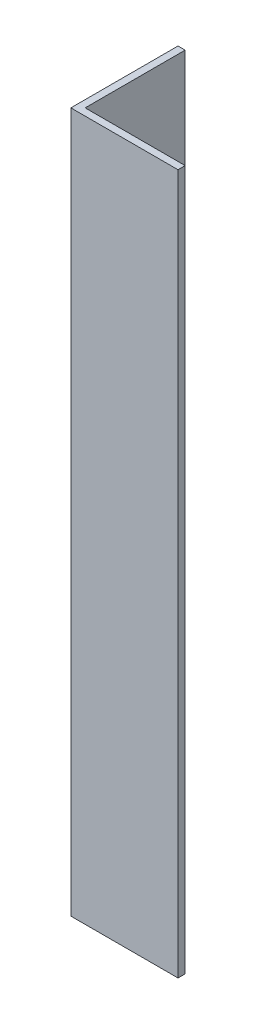
from build123d import *

# Parameters (mm, degrees)
EXTRUDE_1_DEPTH = 98


with BuildPart() as part:
    # Эскиз1 → Бобышка-Вытянуть1 (new body)
    with BuildSketch(Plane(origin=(0, 0, 0), x_dir=(1, 0, 0), z_dir=(0, 1, 0))):
        Polygon((0, 0), (0, 15), (1, 15), (1, 1), (15, 1), (15, 0), align=None)
    extrude(amount=EXTRUDE_1_DEPTH)


solid = part.part
